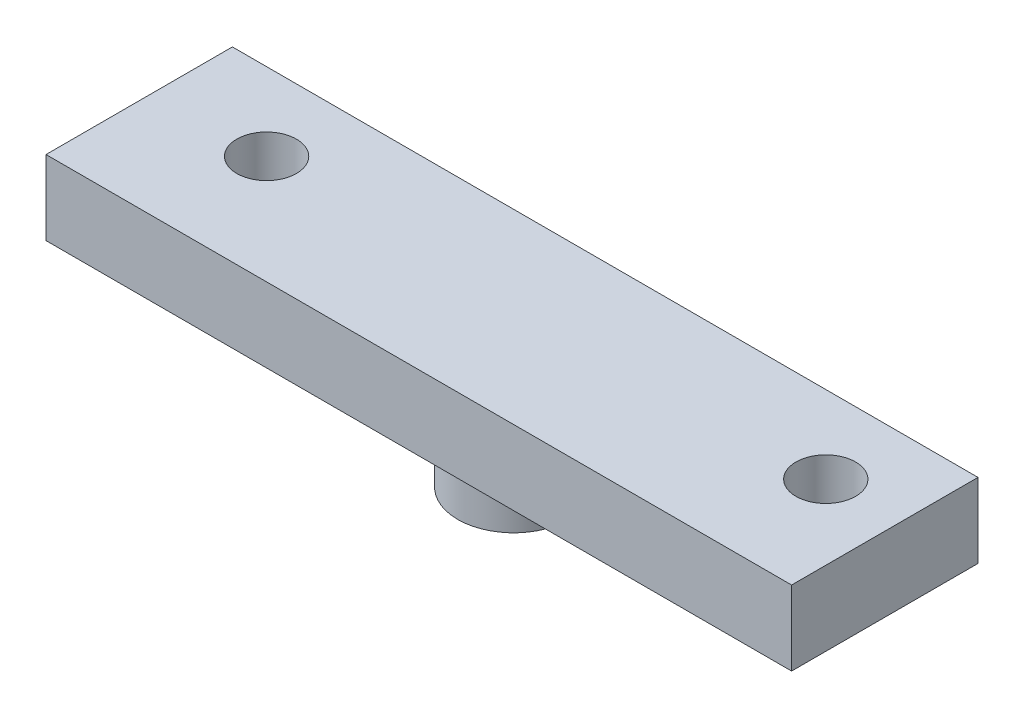
from build123d import *

# Parameters (mm, degrees)
SKETCH1_W           = 20
SKETCH1_H           = 5
SKETCH1_R           = 0.8
BOSS_EXTRUDE1_DEPTH = 2
SKETCH2_R           = 1.5
BOSS_EXTRUDE2_DEPTH = 2


with BuildPart() as part:
    # Sketch1 → Boss-Extrude1 (new body)
    with BuildSketch(Plane(origin=(0, 0, 0), x_dir=(1, 0, 0), z_dir=(0, 1, 0))):
        with Locations((9.677629379, 0.960024777)):
            Rectangle(SKETCH1_W, SKETCH1_H)
        with Locations((17.677629379, 1.377386897)):
            Circle(SKETCH1_R, mode=Mode.SUBTRACT)
        with Locations((2.677629379, 1.377386897)):
            Circle(SKETCH1_R, mode=Mode.SUBTRACT)
    extrude(amount=BOSS_EXTRUDE1_DEPTH)

    # Sketch2 → Boss-Extrude2 (add)
    with BuildSketch(Plane(origin=(0, 0, 0), x_dir=(-1, 0, 0), z_dir=(0, -1, 0))):
        with Locations((-9.677629379, 1.004049849)):
            Circle(SKETCH2_R)
    extrude(amount=BOSS_EXTRUDE2_DEPTH)


solid = part.part
